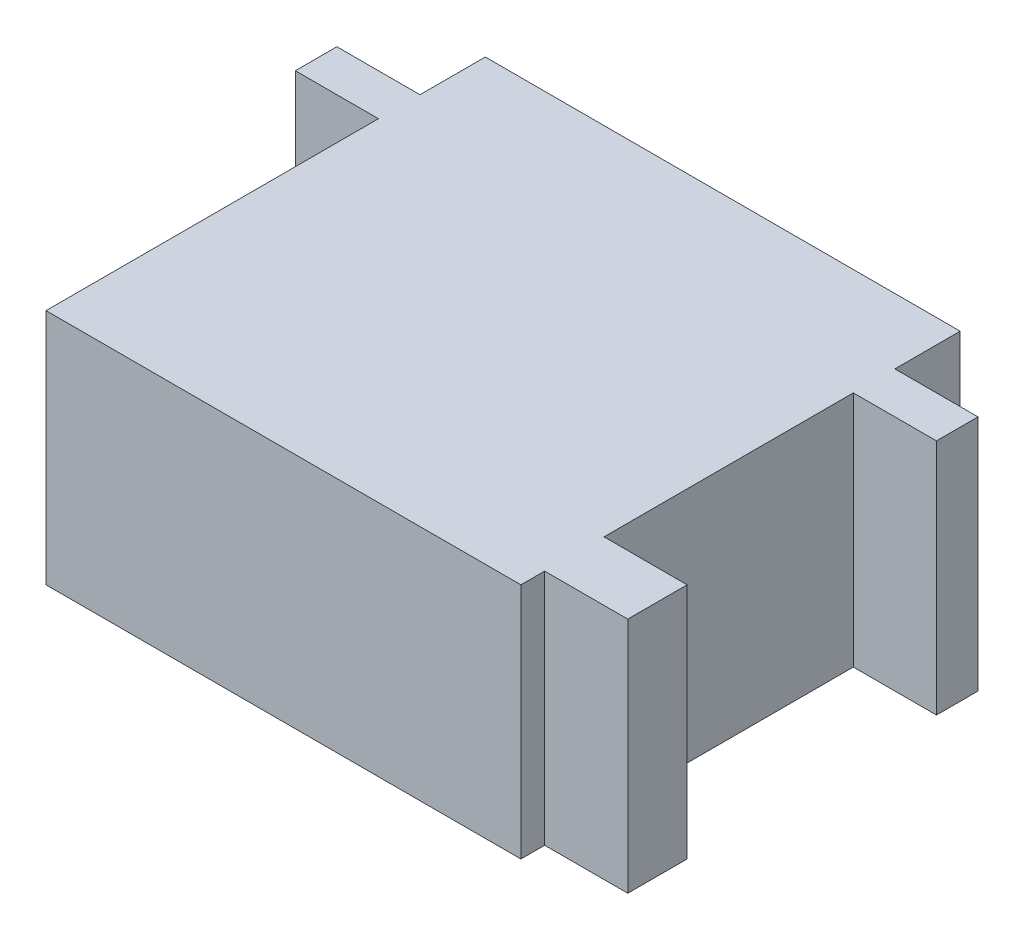
from build123d import *

# Parameters (mm, degrees)
BOSS_EXTRU_1_DEPTH = 20
ESQUISSE2_R        = 3
BOSS_EXTRU_2_DEPTH = 5


with BuildPart() as part:
    # Esquisse1 → Boss.-Extru.1 (new body)
    with BuildSketch(Plane(origin=(0, 0, 0), x_dir=(1, 0, 0), z_dir=(0, 1, 0))):
        Polygon((0, 0), (40, 0), (40, 2), (47, 2), (47, 7), (40, 7), (40, 28), (47, 28), (47, 31.5), (40, 31.5), (40, 37), (0, 37), (0, 31.5), (-7, 31.5), (-7, 28), (0, 28), align=None)
    extrude(amount=BOSS_EXTRU_1_DEPTH)

    # Esquisse2 → Boss.-Extru.2 (add)
    with BuildSketch(Plane(origin=(0, 0, -37), x_dir=(-1, 0, 0), z_dir=(0, 0, -1))):
        with Locations((-30, 10)):
            Circle(ESQUISSE2_R)
    extrude(amount=BOSS_EXTRU_2_DEPTH)


solid = part.part
